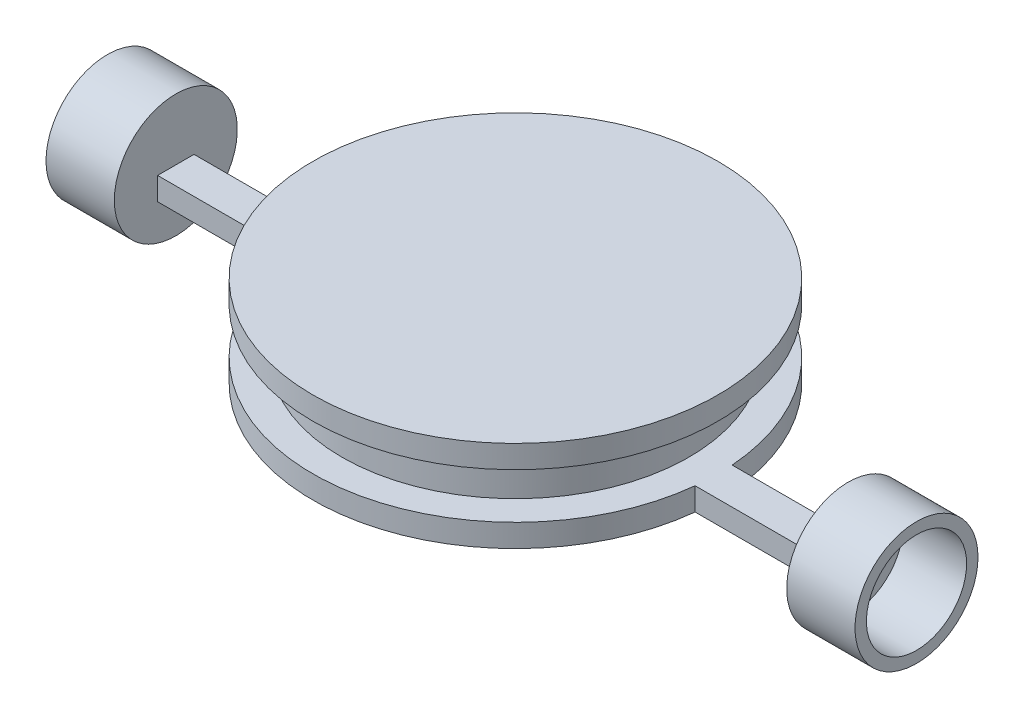
from build123d import *

# Parameters (mm, degrees)
SKETCH1_R           = 44.45
BOSS_EXTRUDE1_DEPTH = 5
SKETCH2_R           = 38.1
BOSS_EXTRUDE2_DEPTH = 10
SKETCH3_R           = 44.45
BOSS_EXTRUDE3_DEPTH = 5
BOSS_EXTRUDE4_DEPTH = 5
SKETCH5_R           = 13.5
BOSS_EXTRUDE5_DEPTH = 15
SKETCH6_R           = 13.5
BOSS_EXTRUDE6_DEPTH = 15
SKETCH7_R           = 11
CUT_EXTRUDE1_DEPTH  = 14
SKETCH8_R           = 11
CUT_EXTRUDE2_DEPTH  = 14


with BuildPart() as part:
    # Sketch1 → Boss-Extrude1 (new body)
    with BuildSketch(Plane(origin=(0, 0, 0), x_dir=(1, 0, 0), z_dir=(0, 1, 0))):
        Circle(SKETCH1_R)
    extrude(amount=BOSS_EXTRUDE1_DEPTH)

    # Sketch2 → Boss-Extrude2 (add)
    with BuildSketch(Plane(origin=(0, 5, 0), x_dir=(1, 0, 0), z_dir=(0, 1, 0))):
        Circle(SKETCH2_R)
    extrude(amount=BOSS_EXTRUDE2_DEPTH)

    # Sketch3 → Boss-Extrude3 (add)
    with BuildSketch(Plane(origin=(0, 15, 0), x_dir=(1, 0, 0), z_dir=(0, 1, 0))):
        Circle(SKETCH3_R)
    extrude(amount=BOSS_EXTRUDE3_DEPTH)

    # Sketch4 → Boss-Extrude4 (add)
    with BuildSketch(Plane(origin=(0, 0, 0), x_dir=(1, 0, 0), z_dir=(0, 1, 0))):
        with BuildLine():
            ThreePointArc((-44.195335285, -4.751298672), (-44.443598423, -0.75436016), (-44.331122698, 3.248701328))
            Line((-44.331122698, 3.248701328), (-73.805449313, 3.248701328))
            Line((-73.805449313, 3.248701328), (-73.805449313, -4.751298672))
            Line((-73.805449313, -4.751298672), (-44.195335285, -4.751298672))
        make_face()
        with BuildLine():
            Line((73.805449313, 3.248701328), (44.331122698, 3.248701328))
            ThreePointArc((44.331122698, 3.248701328), (44.420270733, 1.625437797), (44.45, 0))
            ThreePointArc((44.45, 0), (44.386288161, -2.37905933), (44.195335285, -4.751298672))
            Line((44.195335285, -4.751298672), (73.805449313, -4.751298672))
            Line((73.805449313, -4.751298672), (73.805449313, 3.248701328))
        make_face()
    extrude(amount=BOSS_EXTRUDE4_DEPTH)

    # Sketch5 → Boss-Extrude5 (add)
    with BuildSketch(Plane.ZY.offset(73.805449313)):
        with Locations((0.751298672, 5)):
            Circle(SKETCH5_R)
    extrude(amount=BOSS_EXTRUDE5_DEPTH)

    # Sketch6 → Boss-Extrude6 (add)
    with BuildSketch(Plane(origin=(73.805449313, 0, 0), x_dir=(0, 0, -1), z_dir=(1, 0, 0))):
        with Locations((-0.751298672, 5)):
            Circle(SKETCH6_R)
    extrude(amount=BOSS_EXTRUDE6_DEPTH)

    # Sketch7 → Cut-Extrude1 (cut)
    with BuildSketch(Plane(origin=(88.805449313, 0, 0), x_dir=(0, 0, -1), z_dir=(1, 0, 0))):
        with Locations((-0.751298672, 5)):
            Circle(SKETCH7_R)
    extrude(amount=-CUT_EXTRUDE1_DEPTH, mode=Mode.SUBTRACT)

    # Sketch8 → Cut-Extrude2 (cut)
    with BuildSketch(Plane.ZY.offset(88.805449313)):
        with Locations((0.751298672, 5)):
            Circle(SKETCH8_R)
    extrude(amount=-CUT_EXTRUDE2_DEPTH, mode=Mode.SUBTRACT)


solid = part.part
